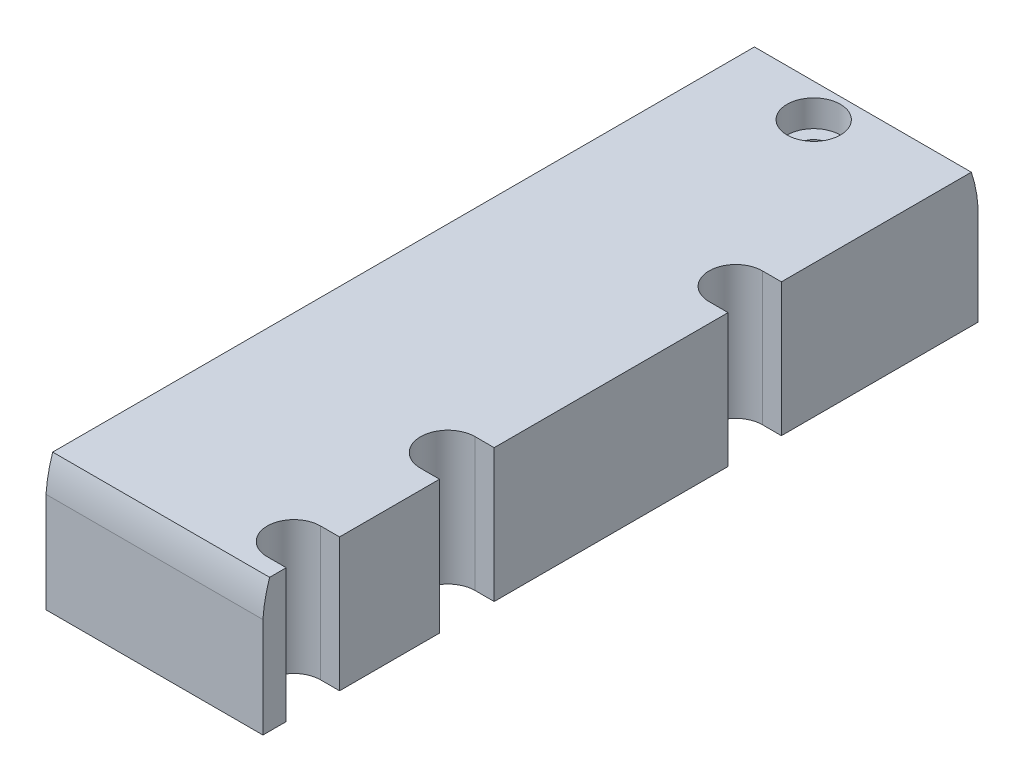
from build123d import *

# Parameters (mm, degrees)
SKETCH1_W               = 32.55
SKETCH1_H               = 107.3
SKETCH1_R               = 2
BOSS_EXTRUDE1_DEPTH     = 20
CUT_EXTRUDE1_DEPTH      = 35
CUT_EXTRUDE1_DEPTH_BACK = 35
CUT_EXTRUDE2_DEPTH      = 35
CUT_EXTRUDE2_DEPTH_BACK = 35
SKETCH4_R               = 4
CUT_EXTRUDE3_DEPTH      = 4
CUT_EXTRUDE4_DEPTH      = 21
CUT_EXTRUDE4_DEPTH_BACK = 21


with BuildPart() as part:
    # Sketch1 → Boss-Extrude1 (new body)
    with BuildSketch(Plane(origin=(0, 0, 0), x_dir=(1, 0, 0), z_dir=(0, 1, 0))):
        with Locations((15.875, 0)):
            Rectangle(SKETCH1_W, SKETCH1_H)
        with Locations((13.5, 47.65)):
            Circle(SKETCH1_R, mode=Mode.SUBTRACT)
    extrude(amount=BOSS_EXTRUDE1_DEPTH)

    # Sketch2 → Cut-Extrude1 (cut, two sides: drawn at the far end of the back side and taken through both)
    with BuildSketch(Plane(origin=(0, 0, 0), x_dir=(0, 0, -1), z_dir=(1, 0, 0)).offset(-CUT_EXTRUDE1_DEPTH_BACK)):
        with BuildLine():
            Line((-53.65, 36.775082183), (-53.65, 15.013329403))
            ThreePointArc((-53.65, 15.013329403), (-47.333294025, 28.233294025), (-33.7, 33.6))
            Line((-33.7, 33.6), (-33.7, 36.775082183))
            Line((-33.7, 36.775082183), (-53.65, 36.775082183))
        make_face()
    extrude(amount=CUT_EXTRUDE1_DEPTH + CUT_EXTRUDE1_DEPTH_BACK, mode=Mode.SUBTRACT)

    # Sketch3 → Cut-Extrude2 (cut, two sides: drawn at the far end of the back side and taken through both)
    with BuildSketch(Plane(origin=(0, 0, 0), x_dir=(0, 0, -1), z_dir=(1, 0, 0)).offset(-CUT_EXTRUDE2_DEPTH_BACK)):
        with BuildLine():
            Line((33.7, 36.775082183), (33.7, 33.6))
            ThreePointArc((33.7, 33.6), (47.333294025, 28.233294025), (53.65, 15.013329403))
            Line((53.65, 15.013329403), (53.65, 36.775082183))
            Line((53.65, 36.775082183), (33.7, 36.775082183))
        make_face()
    extrude(amount=CUT_EXTRUDE2_DEPTH + CUT_EXTRUDE2_DEPTH_BACK, mode=Mode.SUBTRACT)

    # Sketch4 → Cut-Extrude3 (cut)
    with BuildSketch(Plane(origin=(0, 20, 0), x_dir=(1, 0, 0), z_dir=(0, 1, 0))):
        with Locations((13.5, 47.65)):
            Circle(SKETCH4_R)
    extrude(amount=-CUT_EXTRUDE3_DEPTH, mode=Mode.SUBTRACT)

    # Sketch5 → Cut-Extrude4 (cut, two sides: drawn at the far end of the back side and taken through both)
    with BuildSketch(Plane(origin=(0, 20, 0), x_dir=(1, 0, 0), z_dir=(0, 1, 0)).offset(-CUT_EXTRUDE4_DEPTH_BACK)):
        with BuildLine():
            Line((29.3, -27.15), (32.15, -27.15))
            Line((32.15, -27.15), (32.15, -42.15))
            Line((32.15, -42.15), (29.3, -42.15))
            ThreePointArc((29.3, -42.15), (25.3, -46.15), (29.3, -50.15))
            Line((29.3, -50.15), (32.15, -50.15))
            Line((32.15, -50.15), (32.15, -53.65))
            Line((32.15, -53.65), (50, -53.65))
            Line((50, -53.65), (50, 53.65))
            Line((50, 53.65), (32.15, 53.65))
            Line((32.15, 53.65), (32.15, 24.15))
            Line((32.15, 24.15), (29.3, 24.15))
            ThreePointArc((29.3, 24.15), (25.3, 20.15), (29.3, 16.15))
            Line((29.3, 16.15), (32.15, 16.15))
            Line((32.15, 16.15), (32.15, -18.95))
            Line((32.15, -18.95), (29.3, -18.95))
            ThreePointArc((29.3, -18.95), (25.2, -23.05), (29.3, -27.15))
        make_face()
    extrude(amount=CUT_EXTRUDE4_DEPTH + CUT_EXTRUDE4_DEPTH_BACK, mode=Mode.SUBTRACT)


solid = part.part
